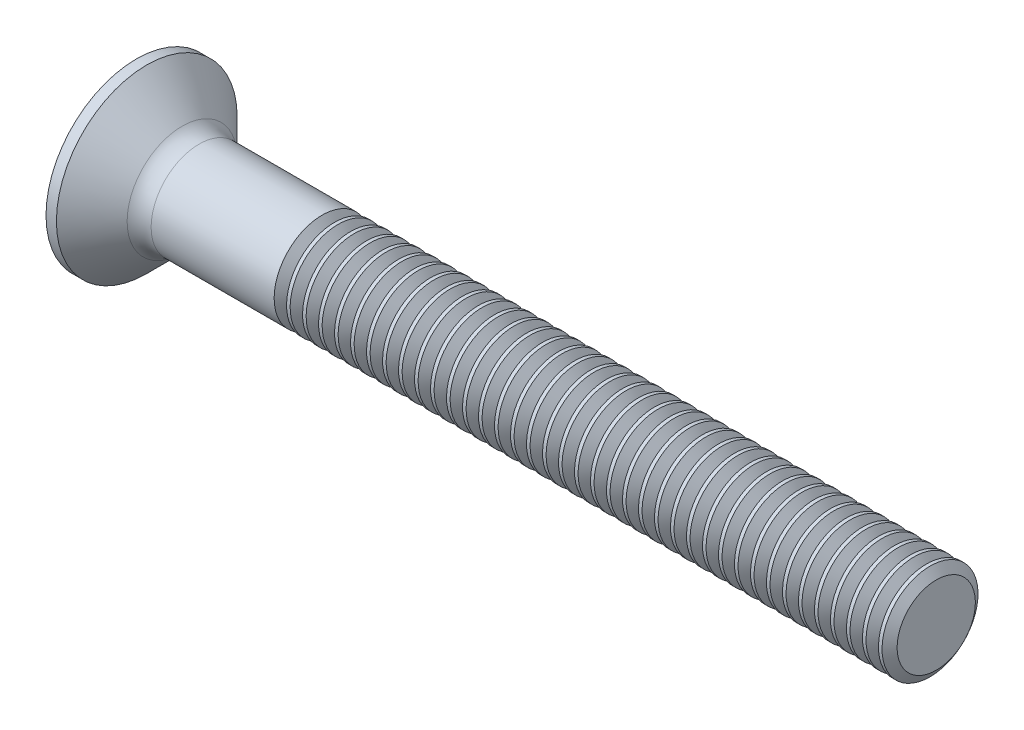
from build123d import *

# Parameters (mm, degrees)
FILLET1_R       = 1.5
SKETCH3_W       = 1.42
SKETCH3_H       = 6.6
SKETCH4_W       = 1.42
SKETCH4_H       = 3.159787024
RECPAT_COUNT    = 2
RECPAT_ANGLE    = 90
THDSCHPAT_COUNT = 39
THDSCHPAT_PITCH = 1


with BuildPart() as part:
    # BodySke → Base-Revolve (revolve)
    with BuildSketch(Plane.XY, mode=Mode.PRIVATE) as base_revolve_sk:
        Polygon((0, 0), (0, 5.65), (0.65, 5.65), (3.3, 3), (50, 3), (50, 0), align=None)
    revolve(base_revolve_sk.sketch.rotate(Axis((-6.35, 0, 0), (1, 0, 0)), 90), axis=Axis((-6.35, 0, 0), (1, 0, 0)))

    # Fillet1
    fillet1_edges = [part.edges().sort_by_distance(p)[0] for p in [
        (3.3, 0, -3),
    ]]
    fillet(fillet1_edges, radius=FILLET1_R)

    # Sketch3 → Recess section 0
    with BuildSketch(Plane.ZY):
        Rectangle(SKETCH3_W, SKETCH3_H)
    # Sketch4 → Recess section 1
    with BuildSketch(Plane.ZY.offset(-3.45)):
        Rectangle(SKETCH4_W, SKETCH4_H)
    recess = loft(mode=Mode.SUBTRACT)

    # RecPat: Recess ×2 about axis
    recpat_axis = Axis((0, 0, 0), (1, 0, 0))
    for i in range(1, RECPAT_COUNT):
        add(recess.rotate(recpat_axis, i * RECPAT_ANGLE / (RECPAT_COUNT - 1)), mode=Mode.SUBTRACT)

    # RecCorSke → RecessCore (revolve, cut)
    with BuildSketch(Plane.XY, mode=Mode.PRIVATE) as recesscore_sk:
        Polygon((0, 0), (0, 1.521747501), (3.45, 1.2805), (3.866059671, 0), align=None)
    revolve(recesscore_sk.sketch.rotate(Axis((-3.175, 0, 0), (1, 0, 0)), 90), axis=Axis((-3.175, 0, 0), (1, 0, 0)), mode=Mode.SUBTRACT)

    # ThdSchSke → ThreadSchematic (revolve, cut)
    with BuildSketch(Plane.XY, mode=Mode.PRIVATE) as threadschematic_sk:
        Polygon((12.000001, -2.4455), (11.61173592, -3), (11.61173592, -3.75), (12.38826608, -3.75), (12.38826608, -3), align=None)
    threadschematic = revolve(threadschematic_sk.sketch.rotate(Axis((-3.175, 0, 0), (1, 0, 0)), 270), axis=Axis((-3.175, 0, 0), (1, 0, 0)), mode=Mode.SUBTRACT)

    # ThdSchPat: ThreadSchematic ×39
    with Locations(*[(i * THDSCHPAT_PITCH, 0, 0) for i in range(1, THDSCHPAT_COUNT)]):
        add(threadschematic, mode=Mode.SUBTRACT)


solid = part.part
